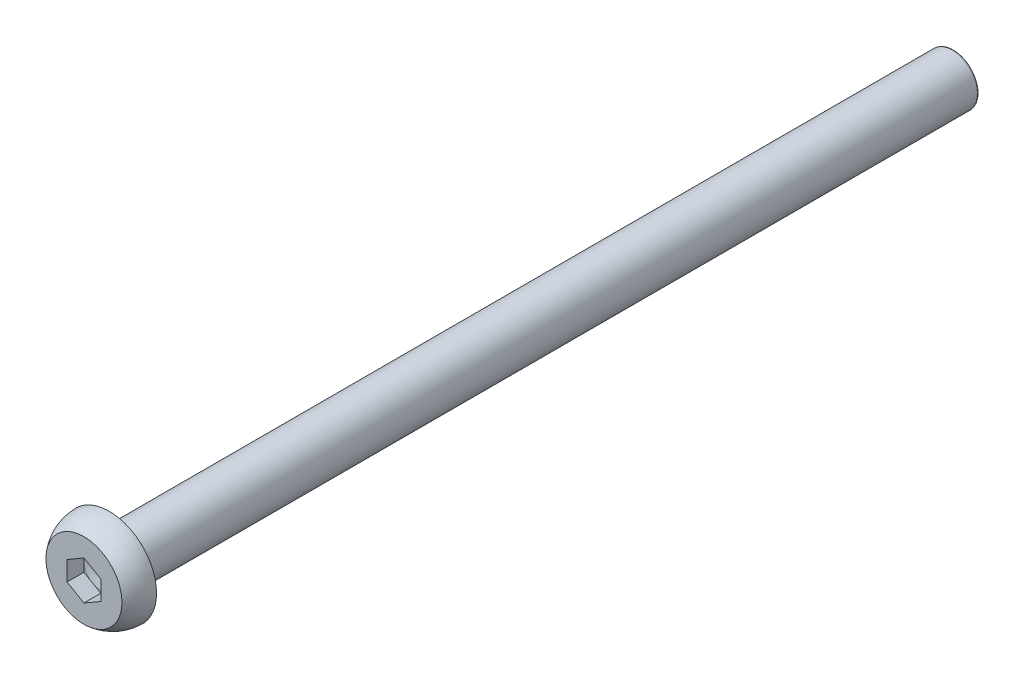
from build123d import *

# Parameters (mm, degrees)
CUT_EXTRUDE_1_DEPTH = 1
FILLET_1_R          = 0.1


with BuildPart() as part:
    # 草图1 → 旋转2 (revolve)
    with BuildSketch(Plane(origin=(0, 0, 0), x_dir=(0, 0, -1), z_dir=(1, 0, 0))):
        with BuildLine():
            Line((0, 2.250343623), (0, 1))
            Line((0, 1), (0, 0))
            Line((0, 0), (1, 0))
            Line((1, 0), (1, 1))
            Line((1, 1), (1.248177586, 0))
            Line((1.248177586, 0), (51.5, 0))
            Line((51.5, 0), (51.5, 1.5))
            Line((51.5, 1.5), (1.5, 1.5))
            Line((1.5, 1.5), (1.5, 2.8))
            ThreePointArc((1.5, 2.8), (0.701231865, 2.658258964), (0, 2.250343623))
        make_face()
    revolve(axis=Axis((0, 0, 0), (0, 0, -1)))

    # 草图2 → 切除-拉伸1 (cut)
    with BuildSketch(Plane.XY):
        Polygon((0, 1.154700538), (-1, 0.577350269), (-1, -0.577350269), (0, -1.154700538), (1, -0.577350269), (1, 0.577350269), align=None)
    extrude(amount=-CUT_EXTRUDE_1_DEPTH, mode=Mode.SUBTRACT)

    # 圆角1
    fillet_1_edges = [part.edges().sort_by_distance(p)[0] for p in [
        (0, -1.5, -51.5),
    ]]
    fillet(fillet_1_edges, radius=FILLET_1_R)


solid = part.part
